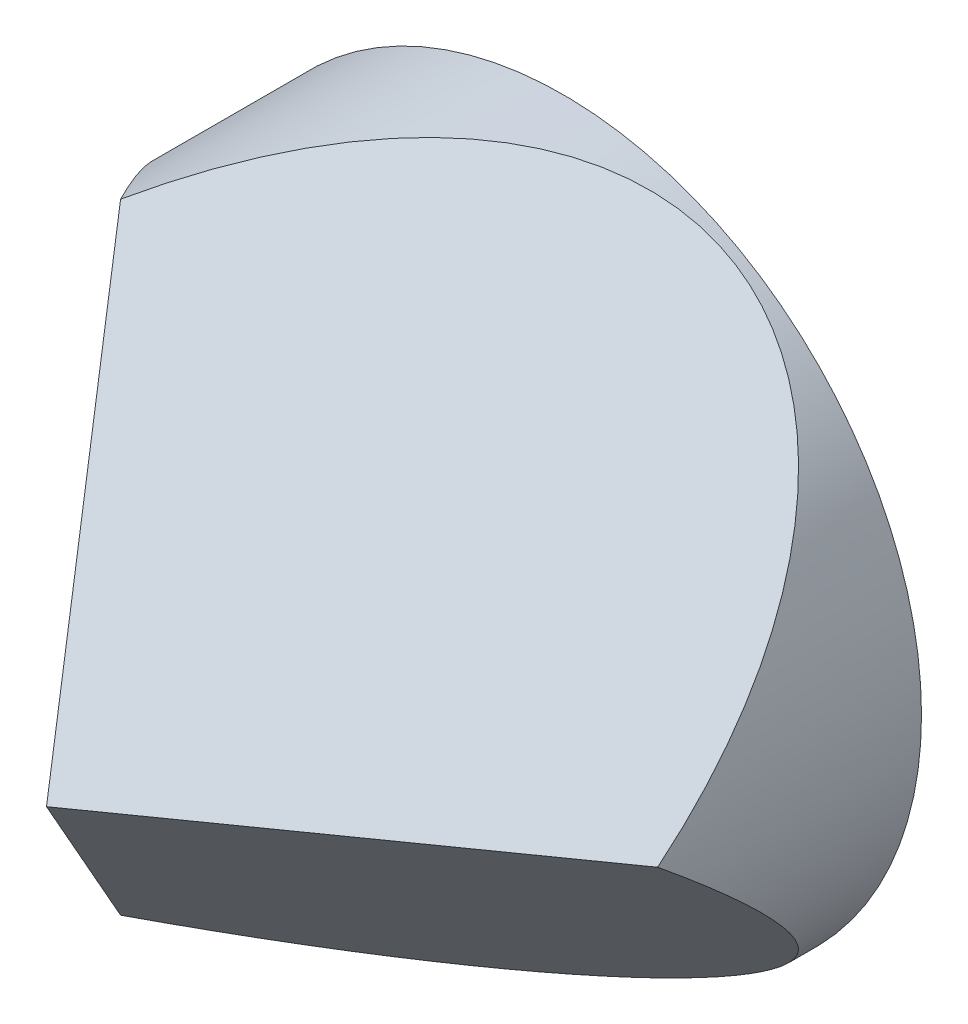
from build123d import *

# Parameters (mm, degrees)
SKETCH_1_R          = 36.25
EXTRUDE_1_DEPTH     = 52.35
CUT_EXTRUDE_1_DEPTH = 39.5
CUT_EXTRUDE_2_DEPTH = 62
CUT_EXTRUDE_3_DEPTH = 53.5


with BuildPart() as part:
    # 草图1 → 凸台-拉伸1 (new body)
    with BuildSketch(Plane.XY):
        Circle(SKETCH_1_R)
    extrude(amount=EXTRUDE_1_DEPTH)

    # 草图2 → 切除-拉伸1 (cut, symmetric)
    with BuildSketch(Plane(origin=(0, 0, 0), x_dir=(1, 0, 0), z_dir=(0, 1, 0))):
        Polygon((0, -52.35), (-40.690324156, 5.182856926), (-40.690324156, -56.656954578), (0, -56.656954578), align=None)
    extrude(amount=CUT_EXTRUDE_1_DEPTH, both=True, mode=Mode.SUBTRACT)

    # 草图4 → 切除-拉伸2 (cut, symmetric)
    with BuildSketch(Plane(origin=(0, 0, 0), x_dir=(0.5, 0.866025404, 0), z_dir=(0.866025404, -0.5, 0))):
        Polygon((0, 52.35), (102.797241837, -92.997060504), (102.797241837, 79.089205692), (0, 79.089205692), align=None)
    extrude(amount=CUT_EXTRUDE_2_DEPTH, both=True, mode=Mode.SUBTRACT)

    # 草图5 → 切除-拉伸3 (cut, symmetric)
    with BuildSketch(Plane(origin=(0, 0, 0), x_dir=(0.5, -0.866025404, 0), z_dir=(-0.866025404, -0.5, 0))):
        Polygon((0, 52.35), (47.788184694, -15.218662816), (47.788184694, 62.081252558), (2.684670532, 62.081252558), align=None)
    extrude(amount=CUT_EXTRUDE_3_DEPTH, both=True, mode=Mode.SUBTRACT)


solid = part.part
